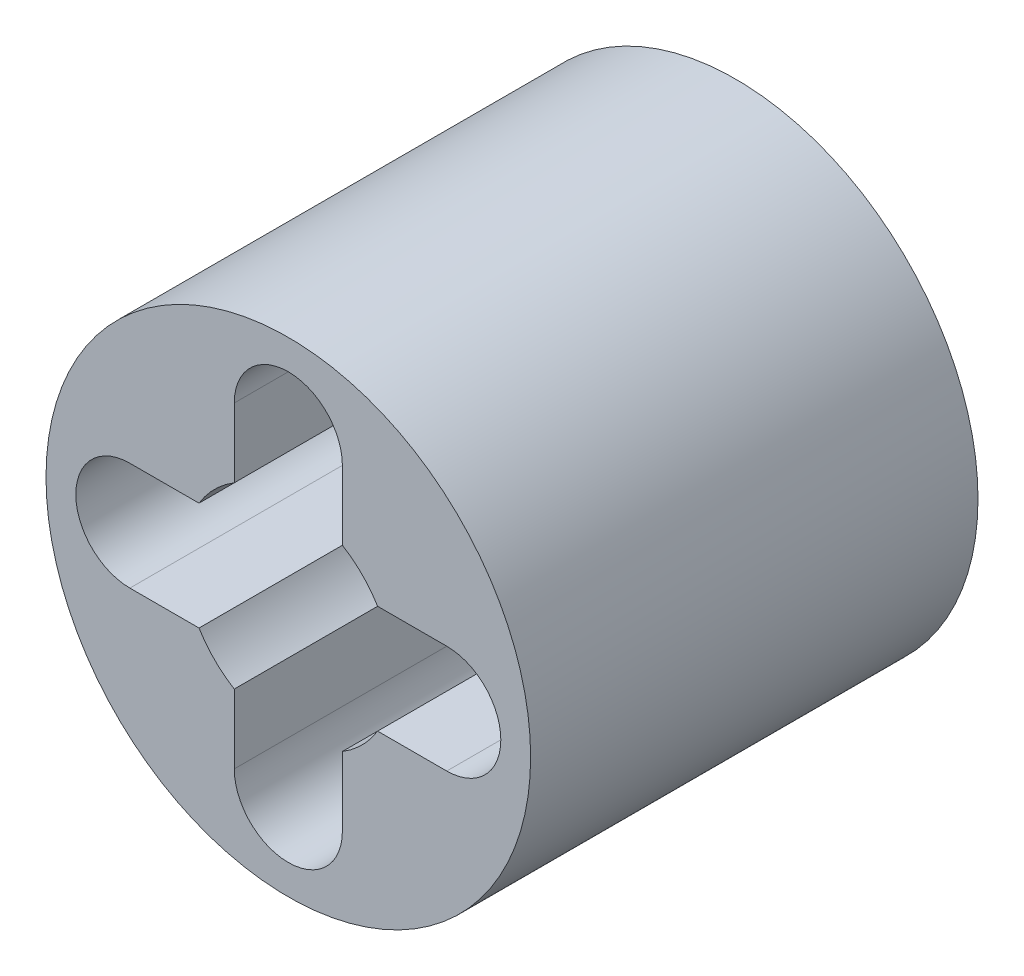
from build123d import *

# Parameters (mm, degrees)
ESQUISSE1_R        = 3.25
BOSS_EXTRU_1_DEPTH = 6


with BuildPart() as part:
    # Esquisse1 → Boss.-Extru.1 (new body)
    with BuildSketch(Plane.XY):
        Circle(ESQUISSE1_R)
        with BuildLine():
            Line((2.125, -0.725), (1.197653957, -0.725))
            ThreePointArc((1.197653957, -0.725), (0.989949494, -0.989949494), (0.725, -1.197653957))
            Line((0.725, -1.197653957), (0.725, -2.125))
            ThreePointArc((0.725, -2.125), (0, -2.85), (-0.725, -2.125))
            Line((-0.725, -2.125), (-0.725, -1.197653957))
            ThreePointArc((-0.725, -1.197653957), (-0.989949494, -0.989949494), (-1.197653957, -0.725))
            Line((-1.197653957, -0.725), (-2.125, -0.725))
            ThreePointArc((-2.125, -0.725), (-2.85, 0), (-2.125, 0.725))
            Line((-2.125, 0.725), (-1.197653957, 0.725))
            ThreePointArc((-1.197653957, 0.725), (-0.989949494, 0.989949494), (-0.725, 1.197653957))
            Line((-0.725, 1.197653957), (-0.725, 2.125))
            ThreePointArc((-0.725, 2.125), (0, 2.85), (0.725, 2.125))
            Line((0.725, 2.125), (0.725, 1.197653957))
            ThreePointArc((0.725, 1.197653957), (0.989949494, 0.989949494), (1.197653957, 0.725))
            Line((1.197653957, 0.725), (2.125, 0.725))
            ThreePointArc((2.125, 0.725), (2.85, 0), (2.125, -0.725))
        make_face(mode=Mode.SUBTRACT)
    extrude(amount=BOSS_EXTRU_1_DEPTH)


solid = part.part
